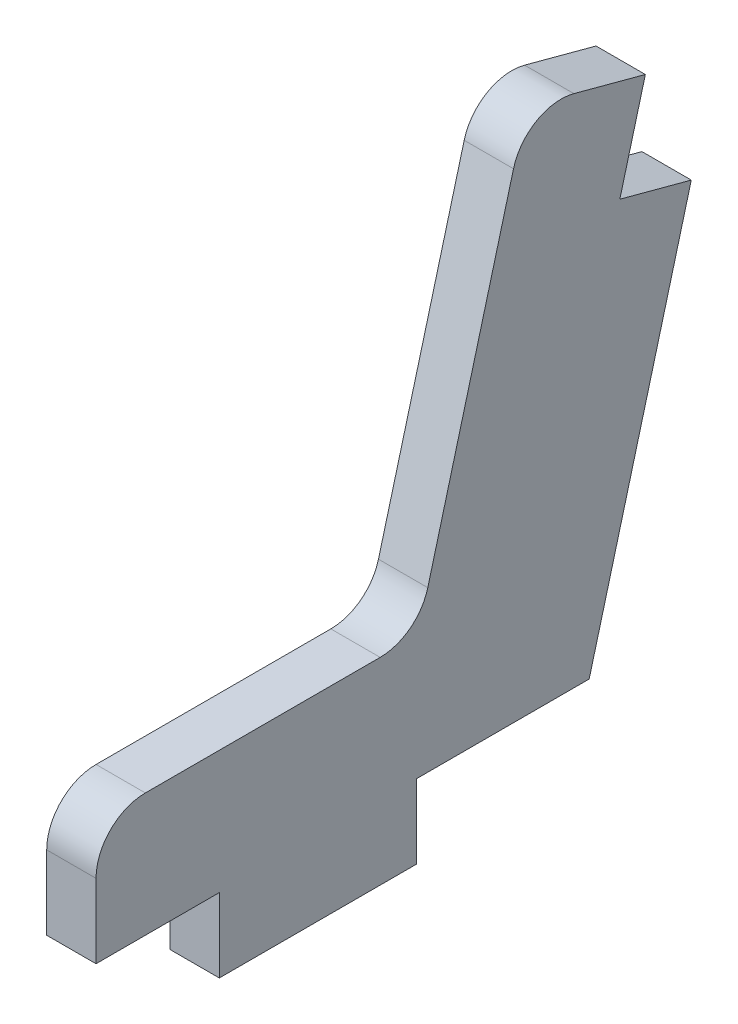
from build123d import *

# Parameters (mm, degrees)
BOSS_EXTRU_1_DEPTH = 2
CONG_1_R           = 2


with BuildPart() as part:
    # Esquisse1 → Boss.-Extru.1 (new body)
    with BuildSketch(Plane(origin=(0, 0, 0), x_dir=(0, 0, -1), z_dir=(1, 0, 0))):
        Polygon((-20.500365221, -12.705219678), (-15.500365221, -12.705219678), (-15.500365221, -15.705219678), (-7.500365221, -15.705219678), (-7.500365221, -12.705219678), (-0.500365221, -12.705219678), (3.6407395, 2.749593542), (0.742962022, 3.526050678), (1.778238202, 7.389753983), (-3.051390929, 8.683849208), (-7.442828702, -7.705219678), (-20.500365221, -7.705219678), align=None)
    extrude(amount=BOSS_EXTRU_1_DEPTH)

    # Congé1
    cong_1_edges = [part.edges().sort_by_distance(p)[0] for p in [
        (1, -7.705219678, 20.500365221),
        (1, -7.705219678, 7.442828702),
        (1, 8.683849208, 3.051390929),
    ]]
    fillet(cong_1_edges, radius=CONG_1_R)


solid = part.part
